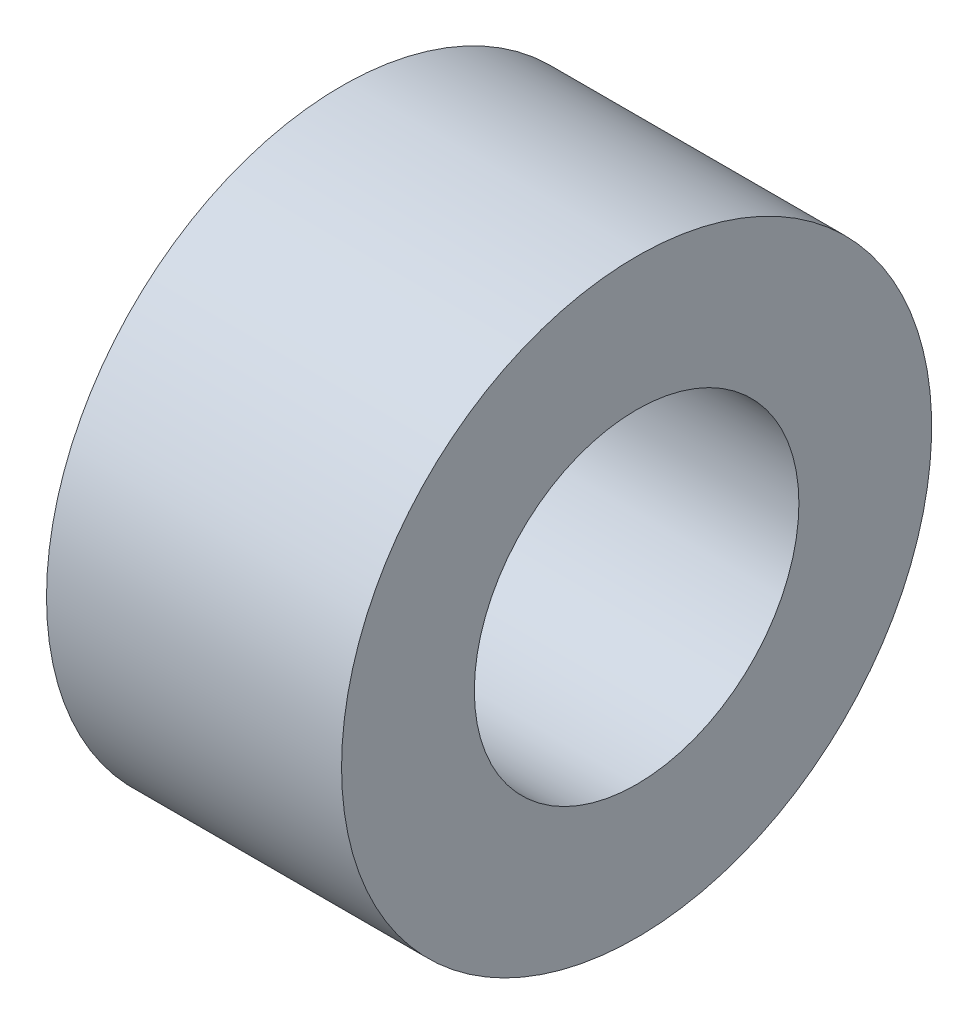
from build123d import *

# Parameters (mm, degrees)
ESQUISSE1_W = 5
ESQUISSE1_H = 2.25


with BuildPart() as part:
    # Esquisse1 → Révolution1 (revolve)
    with BuildSketch(Plane.XY):
        with Locations((2.5, 3.875)):
            Rectangle(ESQUISSE1_W, ESQUISSE1_H)
    revolve(axis=Axis((0, 0, 0), (1, 0, 0)))


solid = part.part
